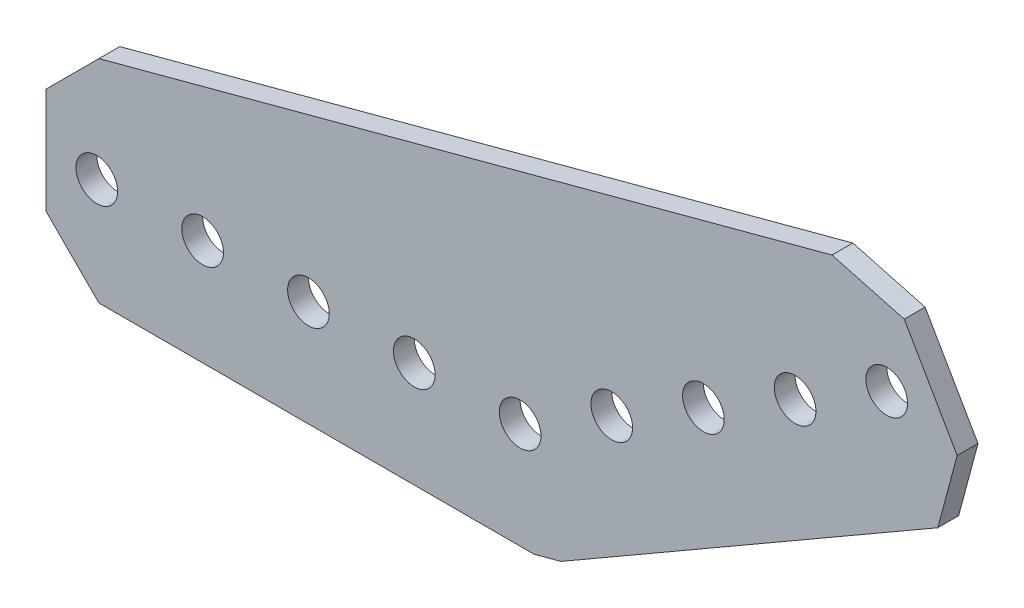
from build123d import *

# Parameters (mm, degrees)
SKETCH1_R           = 2.5
BOSS_EXTRUDE1_DEPTH = 2.5


with BuildPart() as part:
    # Sketch1 → Boss-Extrude1 (new body)
    with BuildSketch(Plane(origin=(0, 0, -1.25), x_dir=(-1, 0, 0), z_dir=(0, 0, -1))):
        Polygon((50.546, 12.7), (-37.42412006, 36.271522628), (-46.098381374, 33.947261314), (-52.448381374, 22.948738686), (-50.12412006, 14.274477372), (-4.902017026, -11.834515988), (-1.671986719, -12.7), (50.546, -12.7), (56.896, -6.35), (56.896, 6.35), align=None)
        with Locations((12.7, 0)):
            Circle(SKETCH1_R, mode=Mode.SUBTRACT)
        with Locations((25.4, 0)):
            Circle(SKETCH1_R, mode=Mode.SUBTRACT)
        Circle(SKETCH1_R, mode=Mode.SUBTRACT)
        with Locations((50.8, 0)):
            Circle(SKETCH1_R, mode=Mode.SUBTRACT)
        with Locations((38.1, 0)):
            Circle(SKETCH1_R, mode=Mode.SUBTRACT)
        with Locations((-43.994090512, 25.4)):
            Circle(SKETCH1_R, mode=Mode.SUBTRACT)
        with Locations((-32.995567884, 19.05)):
            Circle(SKETCH1_R, mode=Mode.SUBTRACT)
        with Locations((-21.997045256, 12.7)):
            Circle(SKETCH1_R, mode=Mode.SUBTRACT)
        with Locations((-10.998522628, 6.35)):
            Circle(SKETCH1_R, mode=Mode.SUBTRACT)
    extrude(amount=-BOSS_EXTRUDE1_DEPTH)


solid = part.part
